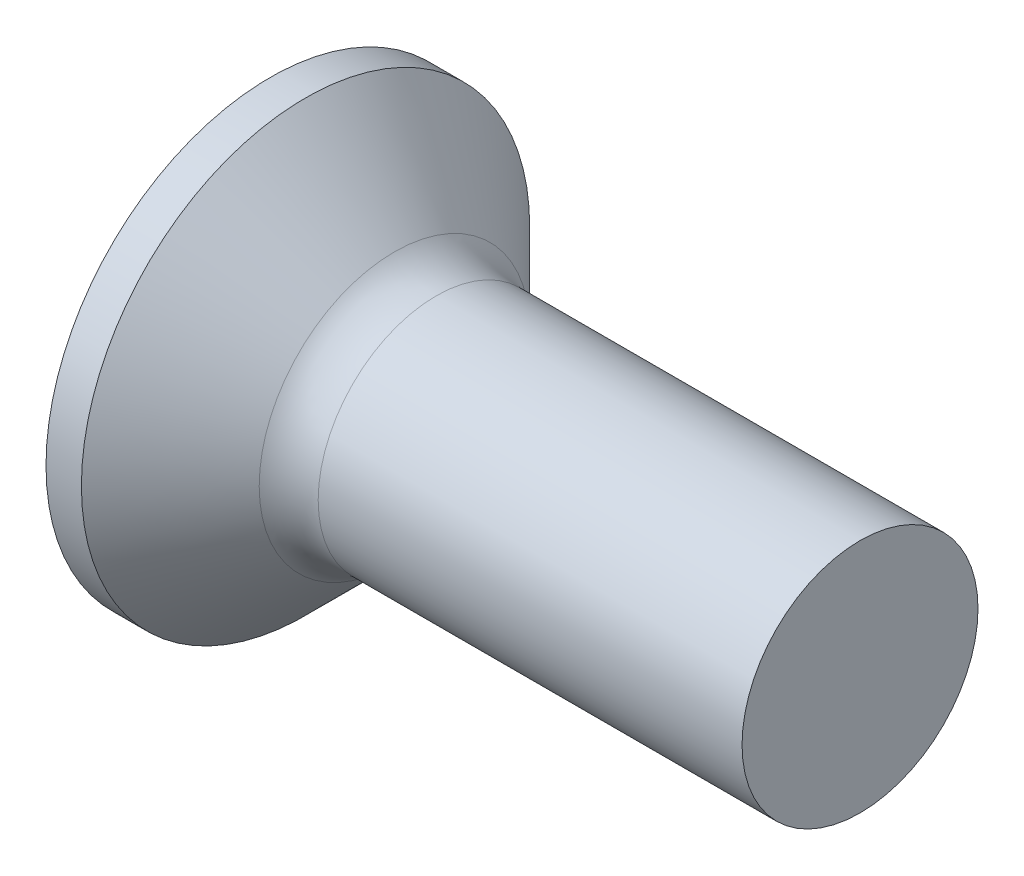
from build123d import *

# Parameters (mm, degrees)
FILLET1_R    = 0.5
SKETCH3_W    = 0.48
SKETCH3_H    = 1.9
SKETCH4_W    = 0.48
SKETCH4_H    = 0.703404182
RECPAT_COUNT = 2
RECPAT_ANGLE = 90


with BuildPart() as part:
    # BodySke → Base-Revolve (revolve)
    with BuildSketch(Plane.XY, mode=Mode.PRIVATE) as base_revolve_sk:
        Polygon((0, 0), (0, 1.9), (0.3, 1.9), (1.2, 1), (5, 1), (5, 0), align=None)
    revolve(base_revolve_sk.sketch.rotate(Axis((-6.35, 0, 0), (1, 0, 0)), 90), axis=Axis((-6.35, 0, 0), (1, 0, 0)))  # turned: the seam where the file's is

    # Fillet1
    fillet1_edges = [part.edges().sort_by_distance(p)[0] for p in [
        (1.2, 0, -1),
    ]]
    fillet(fillet1_edges, radius=FILLET1_R)

    # Sketch3 → Recess section 0
    with BuildSketch(Plane.ZY):
        Rectangle(SKETCH3_W, SKETCH3_H)
    # Sketch4 → Recess section 1
    with BuildSketch(Plane.ZY.offset(-1.2)):
        Rectangle(SKETCH4_W, SKETCH4_H)
    recess = loft(mode=Mode.SUBTRACT)

    # RecPat: Recess ×2 about axis
    recpat_axis = Axis((0, 0, 0), (1, 0, 0))
    for i in range(1, RECPAT_COUNT):
        add(recess.rotate(recpat_axis, i * RECPAT_ANGLE / (RECPAT_COUNT - 1)), mode=Mode.SUBTRACT)

    # RecCorSke → RecessCore (revolve, cut)
    with BuildSketch(Plane.XY, mode=Mode.PRIVATE) as recesscore_sk:
        Polygon((0, 0), (0, 0.439412174), (1.2, 0.3555), (1.315508952, 0), align=None)
    revolve(recesscore_sk.sketch.rotate(Axis((-3.175, 0, 0), (1, 0, 0)), 90), axis=Axis((-3.175, 0, 0), (1, 0, 0)), mode=Mode.SUBTRACT)  # turned: the seam where the file's is


solid = part.part
